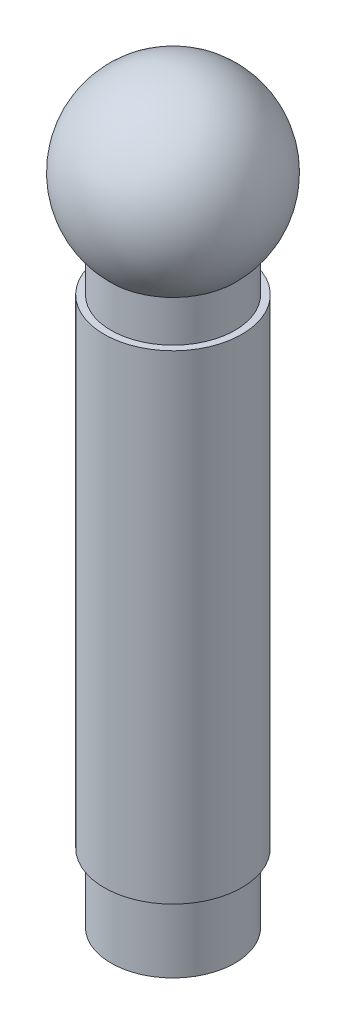
from build123d import *

# Parameters (mm, degrees)
SKETCH2_W          = 5
SKETCH2_H          = 2
CUT_EXTRUDE1_DEPTH = 10


with BuildPart() as part:
    # Sketch1 → Revolve1 (revolve)
    with BuildSketch(Plane.XY):
        with BuildLine():
            Line((4.5, -75.119728996), (4.5, -78.119728996))
            Line((4.5, -78.119728996), (5, -78.119728996))
            Line((5, -78.119728996), (5, -112.929313237))
            Line((5, -112.929313237), (4.5, -112.929313237))
            Line((4.5, -112.929313237), (4.5, -117.929313237))
            Line((4.5, -117.929313237), (0, -117.929313237))
            Line((0, -117.929313237), (0, -63.929313237))
            ThreePointArc((0, -63.929313237), (6.030659269, -68.004205243), (4.5, -75.119728996))
        make_face()
    revolve(axis=Axis((0, -29.874534884, 0), (0, 1, 0)))

    # Sketch2 → Cut-Extrude1 (cut)
    with BuildSketch(Plane(origin=(0, -117.929313237, 0), x_dir=(-1, 0, 0), z_dir=(0, -1, 0))):
        Rectangle(SKETCH2_W, SKETCH2_H)
    extrude(amount=-CUT_EXTRUDE1_DEPTH, mode=Mode.SUBTRACT)


solid = part.part
